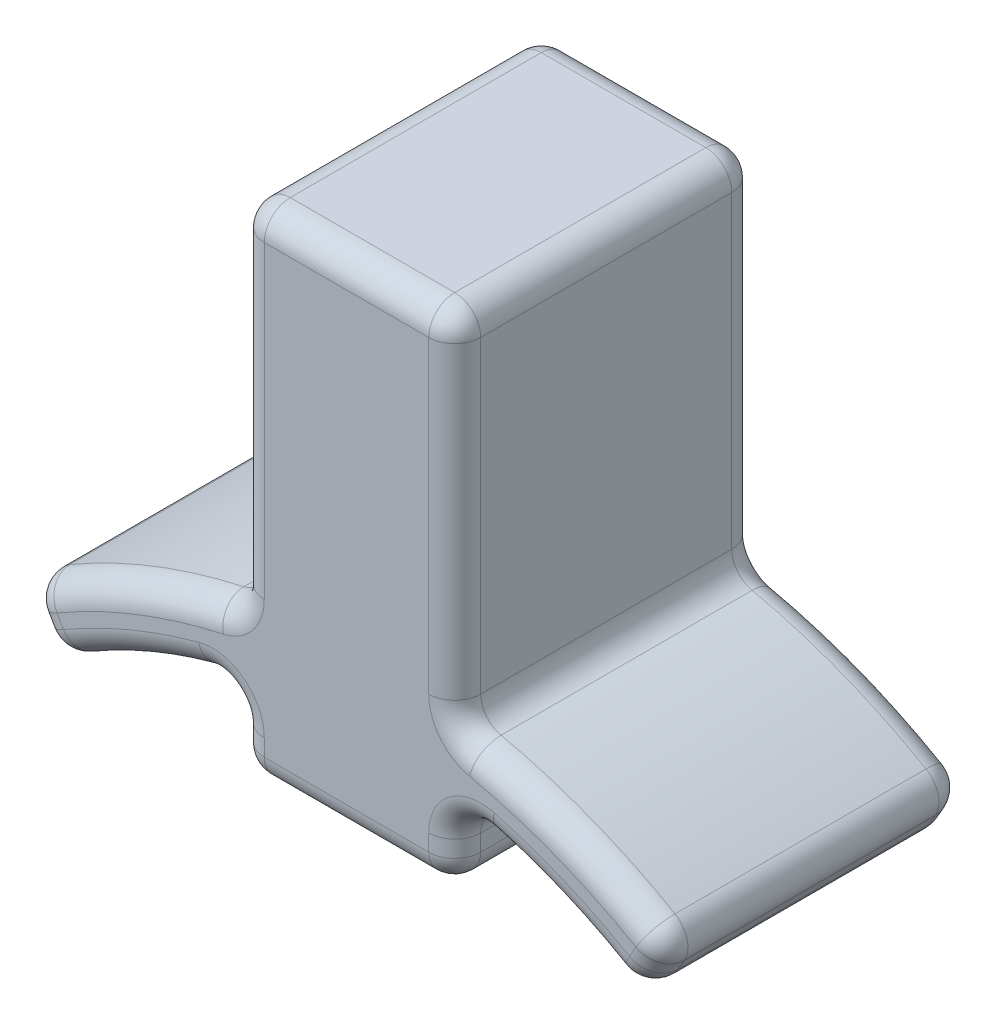
from build123d import *

# Parameters (mm, degrees)
EXTRUDE_1_DEPTH     = 3.5
SKETCH_2_W          = 1.1
SKETCH_2_H          = 2
CUT_EXTRUDE_1_DEPTH = 4.5
FILLET_1_R          = 0.6
FILLET_2_R          = 0.2


with BuildPart() as part:
    # 草图1 → 凸台-拉伸1 (new, symmetric)
    with BuildSketch(Plane.XY):
        with BuildLine():
            Line((-2.5, 1.745172786), (-2.5, 0))
            Line((-2.5, 0), (2.5, 0))
            Line((2.5, 0), (2.5, 1.745172786))
            ThreePointArc((2.5, 1.745172786), (4.706594524, 1.071292635), (6.75, 0))
            Line((6.75, 0), (7.5, 1.299038106))
            ThreePointArc((7.5, 1.299038106), (5.096317816, 2.529350551), (2.5, 3.271301055))
            Line((2.5, 3.271301055), (2.5, 11.498155491))
            Line((2.5, 11.498155491), (-2.5, 11.498155491))
            Line((-2.5, 11.498155491), (-2.5, 3.271301055))
            ThreePointArc((-2.5, 3.271301055), (-5.096317816, 2.529350551), (-7.5, 1.299038106))
            Line((-7.5, 1.299038106), (-6.75, 0))
            ThreePointArc((-6.75, 0), (-4.706594524, 1.071292635), (-2.5, 1.745172786))
        make_face()
    extrude(amount=EXTRUDE_1_DEPTH, both=True)

    # 草图2 → 切除-拉伸1 (cut)
    with BuildSketch(Plane.XZ):
        Rectangle(SKETCH_2_W, SKETCH_2_H)
    extrude(amount=-CUT_EXTRUDE_1_DEPTH, mode=Mode.SUBTRACT)

    # 圆角1
    fillet_1_edges = [part.edges().sort_by_distance(p)[0] for p in [
        (2.5, 0, 0),
        (2.5, 1.745172786, 0),
        (-2.5, 1.745172786, 0),
        (-2.5, 0, 0),
        (2.5, 11.498155491, 0),
        (-2.5, 11.498155491, 0),
        (-5.096317816, 2.529350551, -3.5),
        (-4.706594524, 1.071292635, -3.5),
        (-2.5, 0.872586393, -3.5),
        (0, 0, -3.5),
        (2.5, 0.872586393, -3.5),
        (4.706594524, 1.071292635, -3.5),
        (5.096317816, 2.529350551, -3.5),
        (2.5, 7.384728273, -3.5),
        (0, 11.498155491, -3.5),
        (-2.5, 7.384728273, -3.5),
        (0, 11.498155491, 3.5),
        (2.5, 7.384728273, 3.5),
        (5.096317816, 2.529350551, 3.5),
        (4.706594524, 1.071292635, 3.5),
        (2.5, 0.872586393, 3.5),
        (0, 0, 3.5),
        (-2.5, 0.872586393, 3.5),
        (-4.706594524, 1.071292635, 3.5),
        (-5.096317816, 2.529350551, 3.5),
        (-2.5, 7.384728273, 3.5),
        (-7.5, 1.299038106, 0),
        (-7.125, 0.649519053, 3.5),
        (-6.75, 0, 0),
        (-7.125, 0.649519053, -3.5),
        (6.75, 0, 0),
        (7.125, 0.649519053, 3.5),
        (7.5, 1.299038106, 0),
        (7.125, 0.649519053, -3.5),
        (2.5, 3.271301055, 0),
        (-2.5, 3.271301055, 0),
    ]]
    fillet(fillet_1_edges, radius=FILLET_1_R)

    # 圆角2
    fillet_2_edges = [part.edges().sort_by_distance(p)[0] for p in [
        (0.55, 0, 0),
        (-0.55, 0, 0),
        (0, 0, -1),
        (0, 0, 1),
    ]]
    fillet(fillet_2_edges, radius=FILLET_2_R)


solid = part.part
